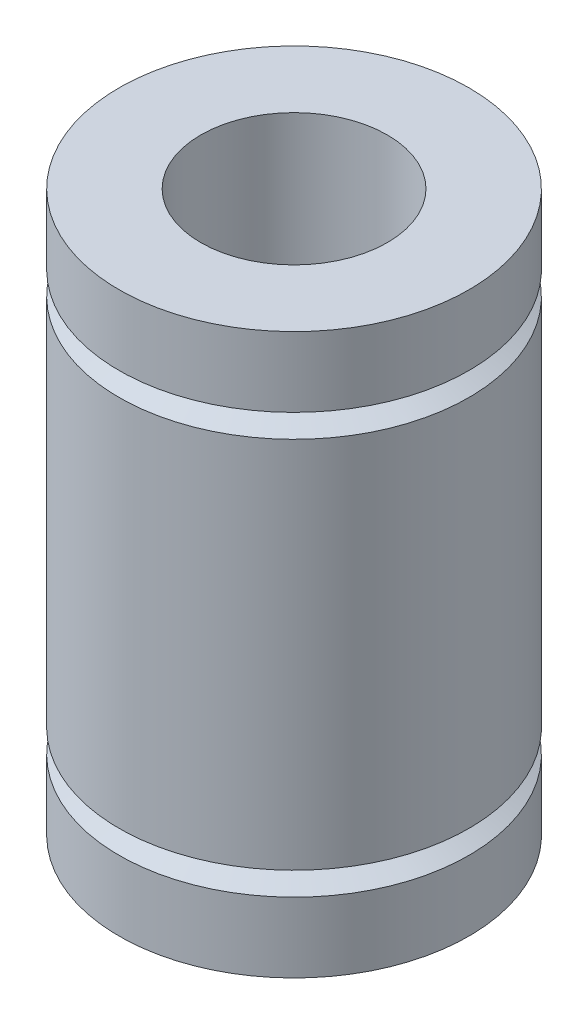
from build123d import *


with BuildPart() as part:
    # 草图1 → 旋转1 (revolve)
    with BuildSketch(Plane.XY):
        Polygon((-52.5, 24), (-56, 24), (-56, 0), (-52.5, 0), (-52.5, 3), (-53.5, 3.5), (-52.5, 4), (-52.5, 20), (-53.5, 20.5), (-52.5, 21), align=None)
    revolve(axis=Axis((-60, 24, 0), (0, -1, 0)))


solid = part.part
